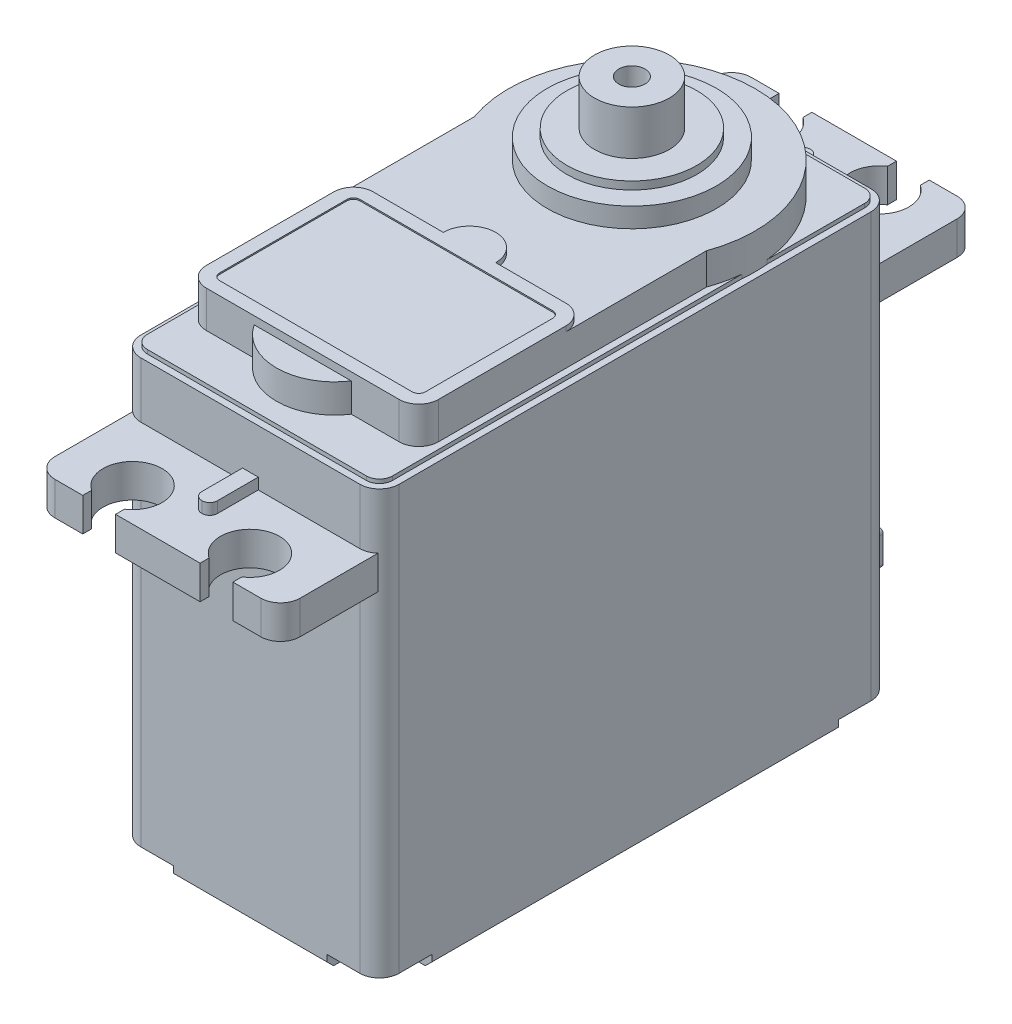
from build123d import *

# Parameters (mm, degrees)
BOSS_EXTRUDE1_DEPTH  = 33.3
BOSS_EXTRUDE2_DEPTH  = 2.55
BOSS_EXTRUDE3_DEPTH  = 2.7
SKETCH6_R            = 4.4225
BOSS_EXTRUDE4_DEPTH  = 2.5
SKETCH7_R            = 6.45
BOSS_EXTRUDE5_DEPTH  = 1.5
SKETCH8_R            = 4.95
BOSS_EXTRUDE6_DEPTH  = 0.6
SKETCH10_R           = 2.85
BOSS_EXTRUDE7_DEPTH  = 3.4
BOSS_EXTRUDE8_DEPTH  = 0.85
SKETCH12_R           = 1
CUT_EXTRUDE1_DEPTH   = 5
BOSS_EXTRUDE9_DEPTH  = 0.4
BOSS_EXTRUDE10_DEPTH = 0.3
BOSS_EXTRUDE11_DEPTH = 0.3
CHAMFER1_SIZE        = 0.5
CUT_EXTRUDE2_DEPTH   = 1
MIRROR2_COPY_1_DEPTH = 1
BOSS_EXTRUDE12_DEPTH = 1.5
BOSS_EXTRUDE13_DEPTH = 5
BOSS_EXTRUDE13_TAPER = 5


with BuildPart() as part:
    # Sketch1 → Boss-Extrude1 (new body)
    with BuildSketch(Plane(origin=(0, 0, 0), x_dir=(1, 0, 0), z_dir=(0, 1, 0))):
        with BuildLine():
            Line((-8.35, -25.58), (8.35, -25.58))
            ThreePointArc((8.35, -25.58), (9.410660172, -25.140660172), (9.85, -24.08))
            Line((9.85, -24.08), (9.85, 11.92))
            ThreePointArc((9.85, 11.92), (9.410660172, 12.980660172), (8.35, 13.42))
            Line((8.35, 13.42), (-8.35, 13.42))
            ThreePointArc((-8.35, 13.42), (-9.410660172, 12.980660172), (-9.85, 11.92))
            Line((-9.85, 11.92), (-9.85, -24.08))
            ThreePointArc((-9.85, -24.08), (-9.410660172, -25.140660172), (-8.35, -25.58))
        make_face()
    extrude(amount=BOSS_EXTRUDE1_DEPTH)

    # Sketch4 → Boss-Extrude2 (add)
    with BuildSketch(Plane(origin=(0, 26.5, 0), x_dir=(1, 0, 0), z_dir=(0, 1, 0))):
        with BuildLine():
            Line((-5.725, 20.47), (-5.725, 19.790828693))
            ThreePointArc((-5.725, 19.790828693), (-4.475, 15.67), (-3.225, 19.790828693))
            Line((-3.225, 19.790828693), (-3.225, 20.47))
            Line((-3.225, 20.47), (3.225, 20.47))
            Line((3.225, 20.47), (3.225, 19.790828693))
            ThreePointArc((3.225, 19.790828693), (4.475, 15.67), (5.725, 19.790828693))
            Line((5.725, 19.790828693), (5.725, 20.47))
            Line((5.725, 20.47), (7.85, 20.47))
            ThreePointArc((7.85, 20.47), (8.910660172, 20.030660172), (9.35, 18.97))
            Line((9.35, 18.97), (9.35, -31.13))
            ThreePointArc((9.35, -31.13), (8.910660172, -32.190660172), (7.85, -32.63))
            Line((7.85, -32.63), (5.725, -32.63))
            Line((5.725, -32.63), (5.725, -31.950828693))
            ThreePointArc((5.725, -31.950828693), (4.475, -27.83), (3.225, -31.950828693))
            Line((3.225, -31.950828693), (3.225, -32.63))
            Line((3.225, -32.63), (-3.225, -32.63))
            Line((-3.225, -32.63), (-3.225, -31.950828693))
            ThreePointArc((-3.225, -31.950828693), (-4.475, -27.83), (-5.725, -31.950828693))
            Line((-5.725, -31.950828693), (-5.725, -32.63))
            Line((-5.725, -32.63), (-7.85, -32.63))
            ThreePointArc((-7.85, -32.63), (-8.910660172, -32.190660172), (-9.35, -31.13))
            Line((-9.35, -31.13), (-9.35, 18.97))
            ThreePointArc((-9.35, 18.97), (-8.910660172, 20.030660172), (-7.85, 20.47))
            Line((-7.85, 20.47), (-5.725, 20.47))
        make_face()
    extrude(amount=BOSS_EXTRUDE2_DEPTH)

    # Sketch5 → Boss-Extrude3 (add)
    with BuildSketch(Plane(origin=(0, 33.3, 0), x_dir=(1, 0, 0), z_dir=(0, 1, 0))):
        with BuildLine():
            Line((-8.85, 0.351798618), (-8.85, -20.08))
            ThreePointArc((-8.85, -20.08), (-8.410660172, -21.140660172), (-7.35, -21.58))
            Line((-7.35, -21.58), (7.35, -21.58))
            ThreePointArc((7.35, -21.58), (8.410660172, -21.140660172), (8.85, -20.08))
            Line((8.85, -20.08), (8.85, 0.351798618))
            ThreePointArc((8.85, 0.351798618), (0, 12.92), (-8.85, 0.351798618))
        make_face()
    extrude(amount=BOSS_EXTRUDE3_DEPTH)

    # Sketch6 → Boss-Extrude4 (add)
    with BuildSketch(Plane(origin=(0, 33.3, 0), x_dir=(1, 0, 0), z_dir=(0, 1, 0))):
        with Locations((0, -19.1575)):
            Circle(SKETCH6_R)
    extrude(amount=BOSS_EXTRUDE4_DEPTH)

    # Sketch7 → Boss-Extrude5 (add)
    with BuildSketch(Plane(origin=(0, 36, 0), x_dir=(1, 0, 0), z_dir=(0, 1, 0))):
        with Locations((0, 3.52)):
            Circle(SKETCH7_R)
    extrude(amount=BOSS_EXTRUDE5_DEPTH)

    # Sketch8 → Boss-Extrude6 (add)
    with BuildSketch(Plane(origin=(0, 37.5, 0), x_dir=(1, 0, 0), z_dir=(0, 1, 0))):
        with Locations((0, 3.52)):
            Circle(SKETCH8_R)
    extrude(amount=BOSS_EXTRUDE6_DEPTH)

    # Sketch10 → Boss-Extrude7 (add)
    with BuildSketch(Plane(origin=(0, 38.1, 0), x_dir=(1, 0, 0), z_dir=(0, 1, 0))):
        with Locations((0, 3.52)):
            Circle(SKETCH10_R)
    extrude(amount=BOSS_EXTRUDE7_DEPTH)

    # Sketch11 → Boss-Extrude8 (add)
    with BuildSketch(Plane(origin=(0, 29.05, 0), x_dir=(1, 0, 0), z_dir=(0, 1, 0))):
        with BuildLine():
            Line((0.61, 13.42), (-0.59, 13.42))
            Line((-0.59, 13.42), (-0.59, 16.53))
            ThreePointArc((-0.59, 16.53), (-0.417193001, 16.947193001), (0, 17.12))
            Line((0, 17.12), (0.02, 17.12))
            ThreePointArc((0.02, 17.12), (0.437193001, 16.947193001), (0.61, 16.53))
            Line((0.61, 16.53), (0.61, 13.42))
        make_face()
        with BuildLine():
            Line((-0.59, -25.58), (-0.59, -28.69))
            ThreePointArc((-0.59, -28.69), (-0.417193001, -29.107193001), (0, -29.28))
            Line((0, -29.28), (0.02, -29.28))
            ThreePointArc((0.02, -29.28), (0.437193001, -29.107193001), (0.61, -28.69))
            Line((0.61, -28.69), (0.61, -25.58))
            Line((0.61, -25.58), (-0.59, -25.58))
        make_face()
    extrude(amount=BOSS_EXTRUDE8_DEPTH)

    # Sketch12 → Cut-Extrude1 (cut)
    with BuildSketch(Plane(origin=(0, 41.5, 0), x_dir=(1, 0, 0), z_dir=(0, 1, 0))):
        with Locations((0, 3.52)):
            Circle(SKETCH12_R)
    extrude(amount=-CUT_EXTRUDE1_DEPTH, mode=Mode.SUBTRACT)

    # Sketch13 → Boss-Extrude9 (add)
    with BuildSketch(Plane(origin=(0, 36, 0), x_dir=(1, 0, 0), z_dir=(0, 1, 0))):
        with BuildLine():
            Line((-8.85, -10.364100691), (-8.85, -20.08))
            ThreePointArc((-8.85, -20.08), (-8.410660172, -21.140660172), (-7.35, -21.58))
            Line((-7.35, -21.58), (7.35, -21.58))
            ThreePointArc((7.35, -21.58), (8.410660172, -21.140660172), (8.85, -20.08))
            Line((8.85, -20.08), (8.85, -10.364100691))
            ThreePointArc((8.85, -10.364100691), (8.410660172, -9.303440519), (7.35, -8.864100691))
            Line((7.35, -8.864100691), (2, -8.864100691))
            ThreePointArc((2, -8.864100691), (0, -6.864100691), (-2, -8.864100691))
            Line((-2, -8.864100691), (-7.35, -8.864100691))
            ThreePointArc((-7.35, -8.864100691), (-8.410660172, -9.303440519), (-8.85, -10.364100691))
        make_face()
        with BuildLine():
            Line((-7.85, -10.364100691), (-7.85, -20.08))
            ThreePointArc((-7.85, -20.08), (-7.703553391, -20.433553391), (-7.35, -20.58))
            Line((-7.35, -20.58), (7.35, -20.58))
            ThreePointArc((7.35, -20.58), (7.703553391, -20.433553391), (7.85, -20.08))
            Line((7.85, -20.08), (7.85, -10.364100691))
            ThreePointArc((7.85, -10.364100691), (7.703553391, -10.010547301), (7.35, -9.864100691))
            Line((7.35, -9.864100691), (-7.35, -9.864100691))
            ThreePointArc((-7.35, -9.864100691), (-7.703553391, -10.010547301), (-7.85, -10.364100691))
        make_face(mode=Mode.SUBTRACT)
    extrude(amount=BOSS_EXTRUDE9_DEPTH)

    # Sketch14 → Boss-Extrude10 (add)
    with BuildSketch(Plane(origin=(0, 36, 0), x_dir=(1, 0, 0), z_dir=(0, 1, 0))):
        with BuildLine():
            Line((-7.85, -10.364100691), (-7.85, -20.08))
            ThreePointArc((-7.85, -20.08), (-7.703553391, -20.433553391), (-7.35, -20.58))
            Line((-7.35, -20.58), (7.35, -20.58))
            ThreePointArc((7.35, -20.58), (7.703553391, -20.433553391), (7.85, -20.08))
            Line((7.85, -20.08), (7.85, -10.364100691))
            ThreePointArc((7.85, -10.364100691), (7.703553391, -10.010547301), (7.35, -9.864100691))
            Line((7.35, -9.864100691), (-7.35, -9.864100691))
            ThreePointArc((-7.35, -9.864100691), (-7.703553391, -10.010547301), (-7.85, -10.364100691))
        make_face()
    extrude(amount=BOSS_EXTRUDE10_DEPTH)

    # Sketch16 → Boss-Extrude11 (add)
    with BuildSketch(Plane(origin=(0, 33.3, 0), x_dir=(1, 0, 0), z_dir=(0, 1, 0))):
        with BuildLine():
            Line((-9.35, 11.92), (-9.35, -24.08))
            ThreePointArc((-9.35, -24.08), (-9.057106781, -24.787106781), (-8.35, -25.08))
            Line((-8.35, -25.08), (8.35, -25.08))
            ThreePointArc((8.35, -25.08), (9.057106781, -24.787106781), (9.35, -24.08))
            Line((9.35, -24.08), (9.35, 11.92))
            ThreePointArc((9.35, 11.92), (9.057106781, 12.627106781), (8.35, 12.92))
            Line((8.35, 12.92), (-8.35, 12.92))
            ThreePointArc((-8.35, 12.92), (-9.057106781, 12.627106781), (-9.35, 11.92))
        make_face()
    extrude(amount=BOSS_EXTRUDE11_DEPTH)

    # Chamfer1
    chamfer1_edges = [part.edges().sort_by_distance(p)[0] for p in [
        (-9.85, 0, 6.08),
        (-9.410660172, 0, -12.980660172),
        (0, 0, -13.42),
        (9.410660172, 0, -12.980660172),
        (9.85, 0, 6.08),
        (9.410660172, 0, 25.140660172),
        (0, 0, 25.58),
        (-9.410660172, 0, 25.140660172),
    ]]
    chamfer(chamfer1_edges, length=CHAMFER1_SIZE)

    # Sketch17 → Cut-Extrude2 (cut)
    with BuildSketch(Plane.XZ):
        with BuildLine():
            Line((-9.85, 21.58), (-9.85, 24.08))
            ThreePointArc((-9.85, 24.08), (-9.410660172, 25.140660172), (-8.35, 25.58))
            Line((-8.35, 25.58), (-5.85, 25.58))
            Line((-5.85, 25.58), (-5.85, 23.08))
            ThreePointArc((-5.85, 23.08), (-6.289339828, 22.019339828), (-7.35, 21.58))
            Line((-7.35, 21.58), (-9.85, 21.58))
        make_face()
    cut_extrude2 = extrude(amount=-CUT_EXTRUDE2_DEPTH, mode=Mode.SUBTRACT)

    # Mirror1: Cut-Extrude2 across plane
    add(cut_extrude2.mirror(Plane(origin=(0, 0, 0), x_dir=(0, 0, 1), z_dir=(1, 0, 0))), mode=Mode.SUBTRACT)

    # Mirror2: Cut-Extrude2 across plane
    add(cut_extrude2.mirror(Plane.XY.offset(6.08)), mode=Mode.SUBTRACT)

    # Mirror2 copy 1 sketch → Mirror2 copy 1 (cut)
    with BuildSketch(Plane(origin=(0, 0, 12.16), x_dir=(-1, 0, 0), z_dir=(0, -1, 0))):
        with BuildLine():
            Line((-9.85, 21.58), (-9.85, 24.08))
            ThreePointArc((-9.85, 24.08), (-9.410660172, 25.140660172), (-8.35, 25.58))
            Line((-8.35, 25.58), (-5.85, 25.58))
            Line((-5.85, 25.58), (-5.85, 23.08))
            ThreePointArc((-5.85, 23.08), (-6.289339828, 22.019339828), (-7.35, 21.58))
            Line((-7.35, 21.58), (-9.85, 21.58))
        make_face()
    extrude(amount=-MIRROR2_COPY_1_DEPTH, mode=Mode.SUBTRACT)

    # Sketch19 → Boss-Extrude12 (add)
    with BuildSketch(Plane(origin=(0, 0, -13.42), x_dir=(-1, 0, 0), z_dir=(0, 0, -1))):
        with BuildLine():
            Line((-2.5, 5.5), (2.5, 5.5))
            ThreePointArc((2.5, 5.5), (3.207106781, 5.207106781), (3.5, 4.5))
            Line((3.5, 4.5), (3.5, 2.5))
            ThreePointArc((3.5, 2.5), (3.207106781, 1.792893219), (2.5, 1.5))
            Line((2.5, 1.5), (-2.5, 1.5))
            ThreePointArc((-2.5, 1.5), (-3.207106781, 1.792893219), (-3.5, 2.5))
            Line((-3.5, 2.5), (-3.5, 4.5))
            ThreePointArc((-3.5, 4.5), (-3.207106781, 5.207106781), (-2.5, 5.5))
        make_face()
    extrude(amount=BOSS_EXTRUDE12_DEPTH)

    # Sketch20 → Boss-Extrude13 (add)
    with BuildSketch(Plane(origin=(0, 0, -14.92), x_dir=(-1, 0, 0), z_dir=(0, 0, -1))):
        with BuildLine():
            Line((-2.5, 1.8), (2.5, 1.8))
            ThreePointArc((2.5, 1.8), (2.994974747, 2.005025253), (3.2, 2.5))
            Line((3.2, 2.5), (3.2, 4.5))
            ThreePointArc((3.2, 4.5), (2.994974747, 4.994974747), (2.5, 5.2))
            Line((2.5, 5.2), (-2.5, 5.2))
            ThreePointArc((-2.5, 5.2), (-2.994974747, 4.994974747), (-3.2, 4.5))
            Line((-3.2, 4.5), (-3.2, 2.5))
            ThreePointArc((-3.2, 2.5), (-2.994974747, 2.005025253), (-2.5, 1.8))
        make_face()
    extrude(amount=BOSS_EXTRUDE13_DEPTH, taper=BOSS_EXTRUDE13_TAPER)


solid = part.part
